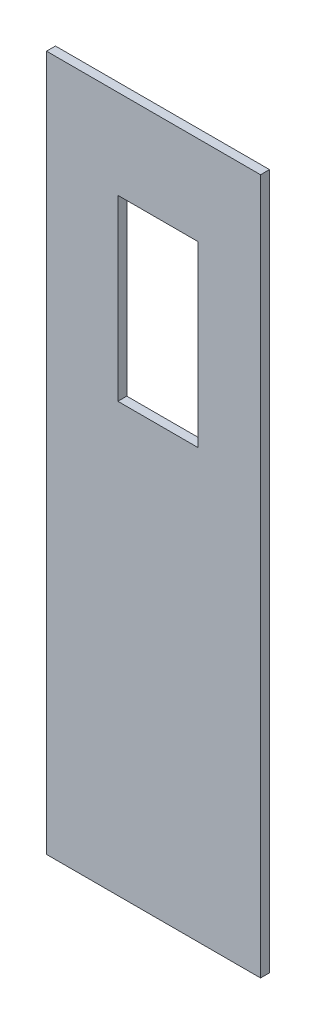
from build123d import *

# Parameters (mm, degrees)
CROQUIS1_W              = 120
CROQUIS1_H              = 390
CROQUIS1_W_2            = 45
CROQUIS1_H_2            = 100
SALIENTE_EXTRUIR1_DEPTH = 5


with BuildPart() as part:
    # Croquis1 → Saliente-Extruir1 (new body)
    with BuildSketch(Plane.XY):
        with Locations((-1.05280459, -130.378696834)):
            Rectangle(CROQUIS1_W, CROQUIS1_H)
        with Locations((1.44719541, -35.378696834)):
            Rectangle(CROQUIS1_W_2, CROQUIS1_H_2, mode=Mode.SUBTRACT)
    extrude(amount=SALIENTE_EXTRUIR1_DEPTH)


solid = part.part
